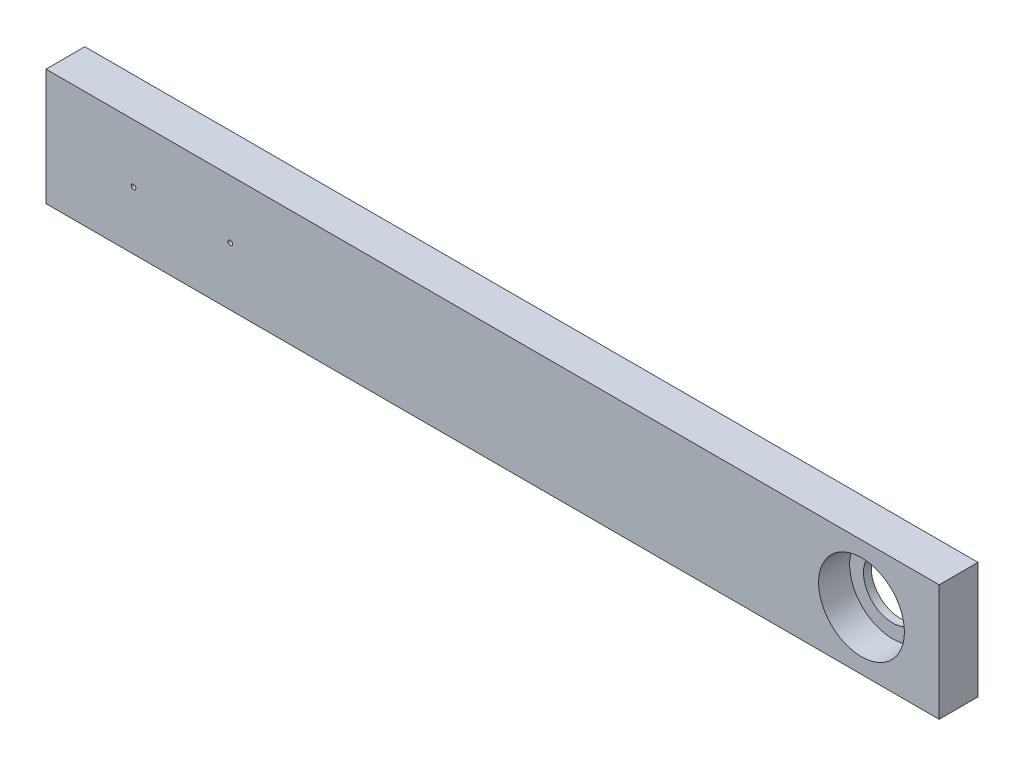
from build123d import *

# Parameters (mm, degrees)
SKETCH1_W           = 230
SKETCH1_H           = 30
SKETCH1_R           = 0.6
SKETCH1_R_2         = 11.05
BOSS_EXTRUDE2_DEPTH = 10
SKETCH1_6_R         = 11.05
SKETCH1_6_R_2       = 7.5
BOSS_EXTRUDE3_DEPTH = 2


with BuildPart() as part:
    # Sketch1 → Boss-Extrude2 (new body)
    with BuildSketch(Plane.XY):
        with Locations((115, 15)):
            Rectangle(SKETCH1_W, SKETCH1_H)
        with Locations((22.55, 15)):
            Circle(SKETCH1_R, mode=Mode.SUBTRACT)
        with Locations((47.45, 15)):
            Circle(SKETCH1_R, mode=Mode.SUBTRACT)
        with Locations((210, 15)):
            Circle(SKETCH1_R_2, mode=Mode.SUBTRACT)
    extrude(amount=BOSS_EXTRUDE2_DEPTH)

    # Sketch1_6 → Boss-Extrude3 (add)
    with BuildSketch(Plane.XY):
        with Locations((210, 15)):
            Circle(SKETCH1_6_R)
        with Locations((210, 15)):
            Circle(SKETCH1_6_R_2, mode=Mode.SUBTRACT)
    extrude(amount=BOSS_EXTRUDE3_DEPTH)


solid = part.part
